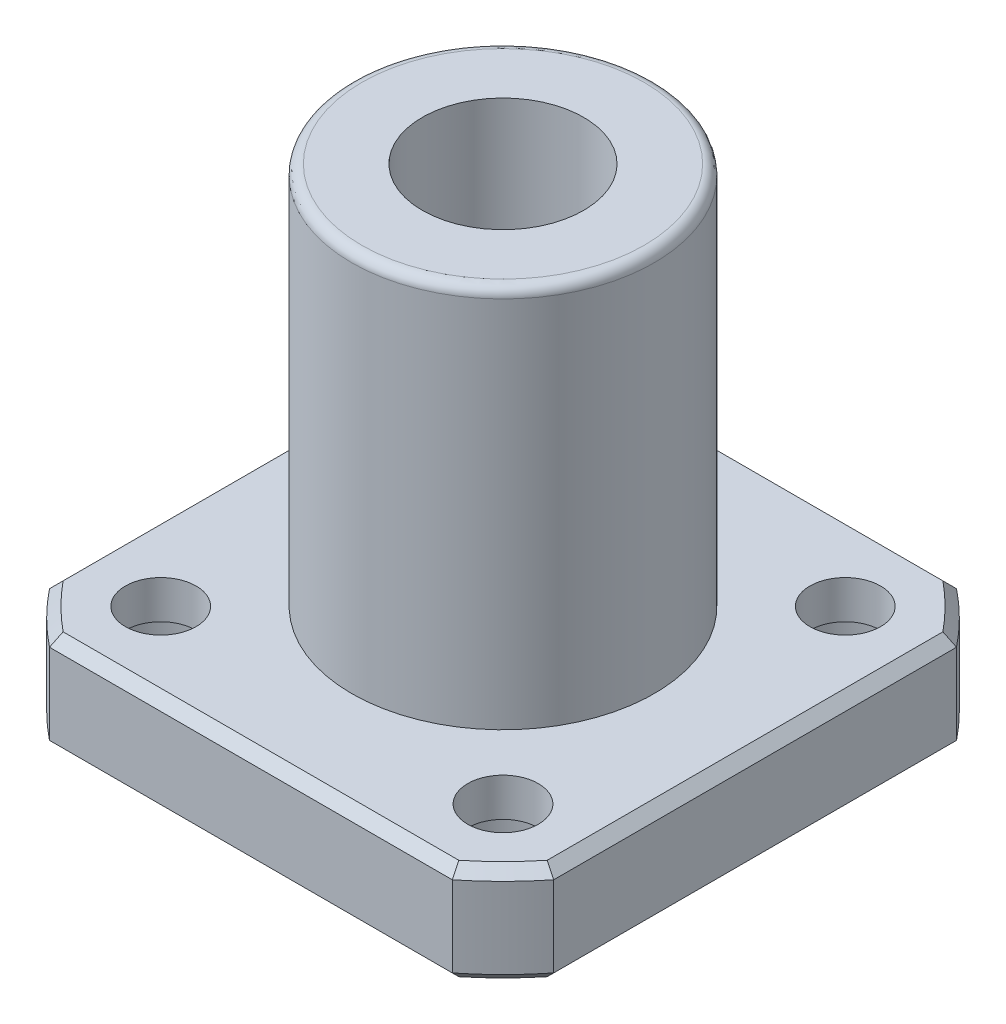
from build123d import *

# Parameters (mm, degrees)
SKETCH_1_R          = 1.75
SKETCH_1_R_2        = 7.5
EXTRUDE_1_DEPTH     = 5
SKETCH_1_3_R        = 7.5
SKETCH_1_3_R_2      = 4
EXTRUDE_2_DEPTH     = 24
SKETCH_2_R          = 3
CUT_EXTRUDE_1_DEPTH = 3.1
CHAMFER_1_SIZE      = 0.5
CHAMFER_2_SIZE      = 0.5
FILLET_1_R          = 0.5


with BuildPart() as part:
    # 草图1 → 凸台-拉伸1 (new body)
    with BuildSketch(Plane(origin=(0, 0, 0), x_dir=(1, 0, 0), z_dir=(0, 1, 0))):
        with BuildLine():
            ThreePointArc((-12.5, -9.987492178), (-11.313708499, -11.313708499), (-9.987492178, -12.5))
            Line((-9.987492178, -12.5), (9.987492178, -12.5))
            ThreePointArc((9.987492178, -12.5), (11.313708499, -11.313708499), (12.5, -9.987492178))
            Line((12.5, -9.987492178), (12.5, 9.987492178))
            ThreePointArc((12.5, 9.987492178), (11.313708499, 11.313708499), (9.987492178, 12.5))
            Line((9.987492178, 12.5), (-9.987492178, 12.5))
            ThreePointArc((-9.987492178, 12.5), (-11.313708499, 11.313708499), (-12.5, 9.987492178))
            Line((-12.5, 9.987492178), (-12.5, -9.987492178))
        make_face()
        with Locations((-8.485281374, -8.485281374)):
            Circle(SKETCH_1_R, mode=Mode.SUBTRACT)
        with Locations((8.485281374, -8.485281374)):
            Circle(SKETCH_1_R, mode=Mode.SUBTRACT)
        with Locations((-8.485281374, 8.485281374)):
            Circle(SKETCH_1_R, mode=Mode.SUBTRACT)
        Circle(SKETCH_1_R_2, mode=Mode.SUBTRACT)
        with Locations((8.485281374, 8.485281374)):
            Circle(SKETCH_1_R, mode=Mode.SUBTRACT)
    extrude(amount=EXTRUDE_1_DEPTH)

    # 草图1<3> → 凸台-拉伸2 (add)
    with BuildSketch(Plane(origin=(0, 0, 0), x_dir=(1, 0, 0), z_dir=(0, 1, 0))):
        Circle(SKETCH_1_3_R)
        Circle(SKETCH_1_3_R_2, mode=Mode.SUBTRACT)
    extrude(amount=EXTRUDE_2_DEPTH)

    # 草图2 → 切除-拉伸1 (cut)
    with BuildSketch(Plane.XZ):
        with Locations((-8.485281374, 8.485281374)):
            Circle(SKETCH_2_R)
        with Locations((8.485281374, 8.485281374)):
            Circle(SKETCH_2_R)
        with Locations((8.485281374, -8.485281374)):
            Circle(SKETCH_2_R)
        with Locations((-8.485281374, -8.485281374)):
            Circle(SKETCH_2_R)
    extrude(amount=-CUT_EXTRUDE_1_DEPTH, mode=Mode.SUBTRACT)

    # 倒角1
    chamfer_1_edges = [part.edges().sort_by_distance(p)[0] for p in [
        (-11.313708499, 5, -11.313708499),
        (0, 5, -12.5),
        (11.313708499, 5, -11.313708499),
        (12.5, 5, 0),
        (11.313708499, 5, 11.313708499),
        (0, 5, 12.5),
        (-11.313708499, 5, 11.313708499),
        (-12.5, 5, 0),
    ]]
    chamfer(chamfer_1_edges, length=CHAMFER_1_SIZE)

    # 倒角2
    chamfer_2_edges = [part.edges().sort_by_distance(p)[0] for p in [
        (11.313708499, 0, -11.313708499),
        (0, 0, -12.5),
        (-11.313708499, 0, -11.313708499),
        (-12.5, 0, 0),
        (-11.313708499, 0, 11.313708499),
        (0, 0, 12.5),
        (12.5, 0, 0),
        (11.313708499, 0, 11.313708499),
    ]]
    chamfer(chamfer_2_edges, length=CHAMFER_2_SIZE)

    # 圆角1
    fillet_1_edges = [part.edges().sort_by_distance(p)[0] for p in [
        (-7.5, 24, 0),
    ]]
    fillet(fillet_1_edges, radius=FILLET_1_R)


solid = part.part
